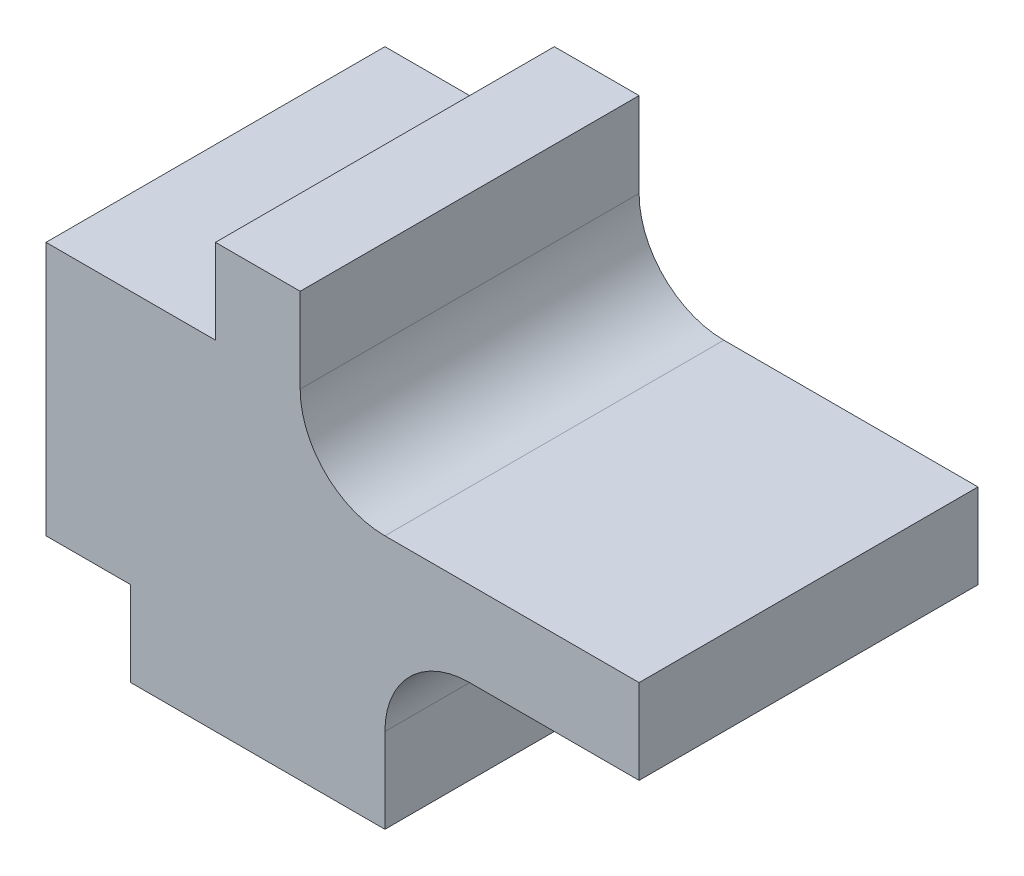
from build123d import *

# Parameters (mm, degrees)
EXTRUDE_1_DEPTH = 20


with BuildPart() as part:
    # 草圖1 → 填料-伸長1 (new body)
    with BuildSketch(Plane.XY):
        with BuildLine():
            Line((0, 0), (15, 0))
            Line((15, 0), (15, 5))
            ThreePointArc((15, 5), (16.464466094, 8.535533906), (20, 10))
            Line((20, 10), (30, 10))
            Line((30, 10), (30, 15))
            Line((30, 15), (15, 15))
            ThreePointArc((15, 15), (11.464466094, 16.464466094), (10, 20))
            Line((10, 20), (10, 25))
            Line((10, 25), (5, 25))
            Line((5, 25), (5, 20))
            Line((5, 20), (-5, 20))
            Line((-5, 20), (-5, 5))
            Line((-5, 5), (0, 5))
            Line((0, 5), (0, 0))
        make_face()
    extrude(amount=EXTRUDE_1_DEPTH)


solid = part.part
